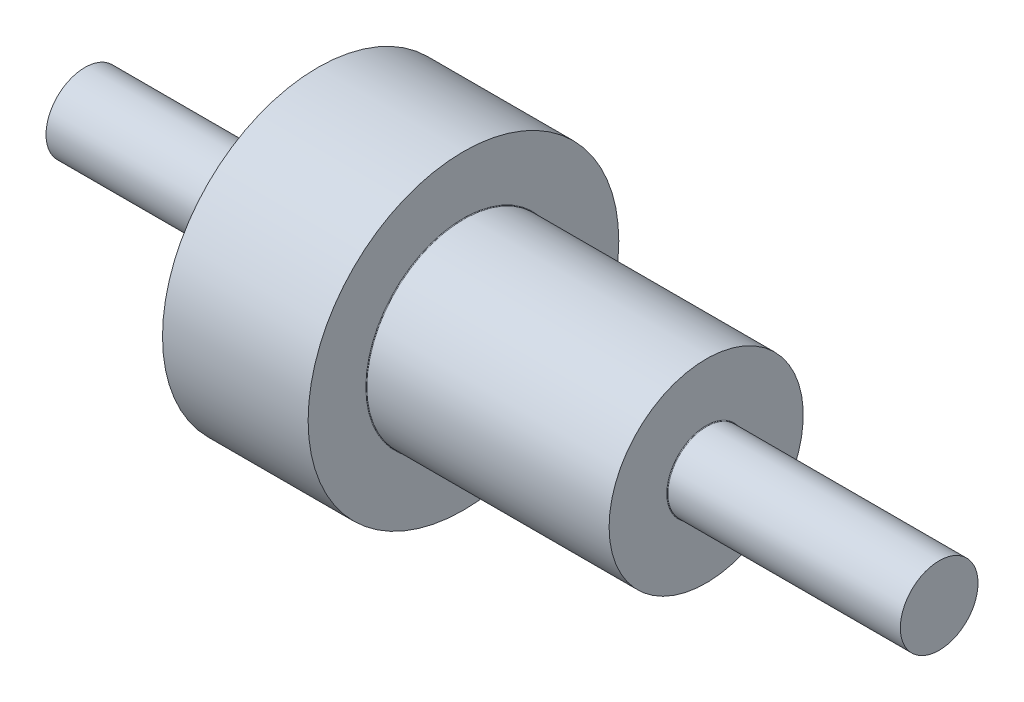
from build123d import *

# Parameters (mm, degrees)
CROQUIS2_R              = 2
SALIENTE_EXTRUIR1_DEPTH = 8
CROQUIS3_R              = 2
SALIENTE_EXTRUIR2_DEPTH = 8
REDONDEO1_R             = 0.03
REDONDEO2_R             = 0.03


with BuildPart() as part:
    # Croquis1 → Revolución1 (revolve)
    with BuildSketch(Plane.XY, mode=Mode.PRIVATE) as revoluci_n1_sk:
        Polygon((0, 0), (0, 2), (4, 2), (4, 8), (11.5, 8), (11.5, 5), (24, 5), (24, 2), (28, 2), (28, 0), align=None)
    revolve(revoluci_n1_sk.sketch.rotate(Axis((0, 0, 0), (1, 0, 0)), 90), axis=Axis((0, 0, 0), (1, 0, 0)))

    # Croquis2 → Saliente-Extruir1 (add)
    with BuildSketch(Plane.ZY):
        Circle(CROQUIS2_R)
    extrude(amount=SALIENTE_EXTRUIR1_DEPTH)

    # Croquis3 → Saliente-Extruir2 (add)
    with BuildSketch(Plane(origin=(28, 0, 0), x_dir=(0, 0, -1), z_dir=(1, 0, 0))):
        with Locations(Location((0, 0, 0), (0, 0, 180))):
            Circle(CROQUIS3_R)
    extrude(amount=SALIENTE_EXTRUIR2_DEPTH)

    # Redondeo1
    redondeo1_edges = [part.edges().sort_by_distance(p)[0] for p in [
        (4, 0, -2),
    ]]
    fillet(redondeo1_edges, radius=REDONDEO1_R)

    # Redondeo2
    redondeo2_edges = [part.edges().sort_by_distance(p)[0] for p in [
        (11.5, 0, -5),
        (24, 0, -2),
    ]]
    fillet(redondeo2_edges, radius=REDONDEO2_R)


solid = part.part
